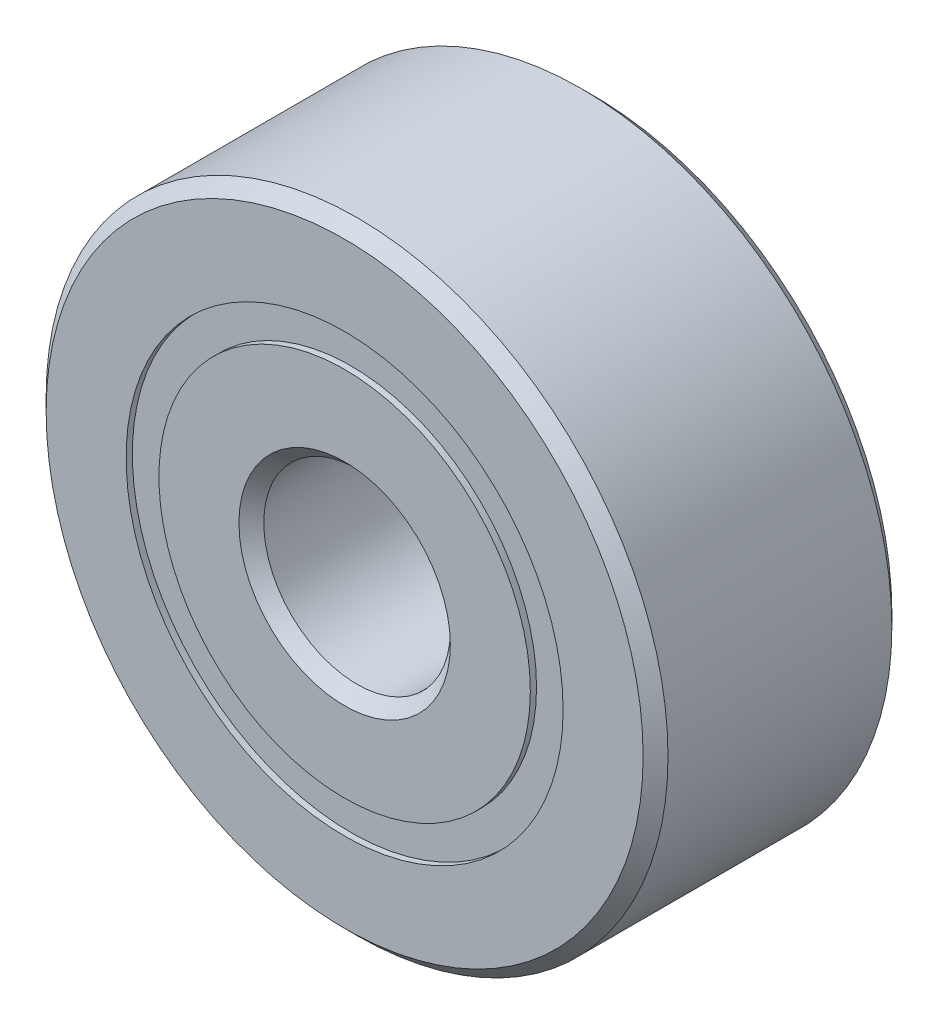
from build123d import *

# Parameters (mm, degrees)
CIRPATTERN1_COUNT = 12
SKETCH5_W         = 0.972810551
SKETCH5_H         = 0.527472528


with BuildPart() as part:
    # Sketch1 → Revolve1 (revolve)
    with BuildSketch(Plane(origin=(0, 0, 0), x_dir=(0, 0, -1), z_dir=(1, 0, 0))):
        with BuildLine():
            Line((1.8, 5), (-1.8, 5))
            Line((-1.8, 5), (-2, 4.8))
            Line((-2, 4.8), (-2, 3.513736264))
            Line((-2, 3.513736264), (-0.888888889, 3.513736264))
            ThreePointArc((-0.888888889, 3.513736264), (0, 4.177189449), (0.888888889, 3.513736264))
            Line((0.888888889, 3.513736264), (2, 3.513736264))
            Line((2, 3.513736264), (2, 4.8))
            Line((2, 4.8), (1.8, 5))
        make_face()
    revolve(axis=Axis((0, 0, 2), (0, 0, -1)))


with BuildPart() as body_2:
    # Sketch3 → Revolve3 (revolve)
    with BuildSketch(Plane(origin=(0, 0, 0), x_dir=(0, 0, -1), z_dir=(1, 0, 0))):
        with BuildLine():
            Line((-2, 2.986263736), (-0.888888889, 2.986263736))
            ThreePointArc((-0.888888889, 2.986263736), (0, 2.322810551), (0.888888889, 2.986263736))
            Line((0.888888889, 2.986263736), (2, 2.986263736))
            Line((2, 2.986263736), (2, 1.7))
            Line((2, 1.7), (1.8, 1.5))
            Line((1.8, 1.5), (-1.8, 1.5))
            Line((-1.8, 1.5), (-2, 1.7))
            Line((-2, 1.7), (-2, 2.986263736))
        make_face()
    revolve(axis=Axis((0, 0, 2), (0, 0, -1)))


with BuildPart() as body_3:
    # Sketch4 → Revolve4 (revolve)
    with BuildSketch(Plane(origin=(0, 0, 0), x_dir=(0, 0, -1), z_dir=(1, 0, 0))):
        with BuildLine():
            Line((-0.927189449, 3.25), (0.927189449, 3.25))
            ThreePointArc((0.927189449, 3.25), (0, 4.177189449), (-0.927189449, 3.25))
        make_face()
    revolve(axis=Axis((0, 3.25, 0.927189449), (0, 0, -1)))


with BuildPart() as cirpattern1_1:
    # CirPattern1: pattern copy
    add(body_3.part.rotate(Axis((0, 0, -2), (0, 0, 1)), 1 * 360 / CIRPATTERN1_COUNT))


with BuildPart() as cirpattern1_2:
    # CirPattern1: pattern copy
    add(body_3.part.rotate(Axis((0, 0, -2), (0, 0, 1)), 2 * 360 / CIRPATTERN1_COUNT))


with BuildPart() as cirpattern1_3:
    # CirPattern1: pattern copy
    add(body_3.part.rotate(Axis((0, 0, -2), (0, 0, 1)), 3 * 360 / CIRPATTERN1_COUNT))


with BuildPart() as cirpattern1_4:
    # CirPattern1: pattern copy
    add(body_3.part.rotate(Axis((0, 0, -2), (0, 0, 1)), 4 * 360 / CIRPATTERN1_COUNT))


with BuildPart() as cirpattern1_5:
    # CirPattern1: pattern copy
    add(body_3.part.rotate(Axis((0, 0, -2), (0, 0, 1)), 5 * 360 / CIRPATTERN1_COUNT))


with BuildPart() as cirpattern1_6:
    # CirPattern1: pattern copy
    add(body_3.part.rotate(Axis((0, 0, -2), (0, 0, 1)), 6 * 360 / CIRPATTERN1_COUNT))


with BuildPart() as cirpattern1_7:
    # CirPattern1: pattern copy
    add(body_3.part.rotate(Axis((0, 0, -2), (0, 0, 1)), 7 * 360 / CIRPATTERN1_COUNT))


with BuildPart() as cirpattern1_8:
    # CirPattern1: pattern copy
    add(body_3.part.rotate(Axis((0, 0, -2), (0, 0, 1)), 8 * 360 / CIRPATTERN1_COUNT))


with BuildPart() as cirpattern1_9:
    # CirPattern1: pattern copy
    add(body_3.part.rotate(Axis((0, 0, -2), (0, 0, 1)), 9 * 360 / CIRPATTERN1_COUNT))


with BuildPart() as cirpattern1_10:
    # CirPattern1: pattern copy
    add(body_3.part.rotate(Axis((0, 0, -2), (0, 0, 1)), 10 * 360 / CIRPATTERN1_COUNT))


with BuildPart() as cirpattern1_11:
    # CirPattern1: pattern copy
    add(body_3.part.rotate(Axis((0, 0, -2), (0, 0, 1)), 11 * 360 / CIRPATTERN1_COUNT))


with BuildPart() as body_15:
    # Sketch5 → Revolve5 (revolve)
    with BuildSketch(Plane(origin=(0, 0, 0), x_dir=(0, 0, -1), z_dir=(1, 0, 0))):
        with Locations((-1.413594725, 3.25)):
            Rectangle(SKETCH5_W, SKETCH5_H)
        with Locations((1.413594725, 3.25)):
            Rectangle(SKETCH5_W, SKETCH5_H)
    revolve(axis=Axis((0, 0, 2), (0, 0, -1)))


solid = Compound([part.part, body_2.part, body_3.part, cirpattern1_1.part, cirpattern1_2.part, cirpattern1_3.part, cirpattern1_4.part, cirpattern1_5.part, cirpattern1_6.part, cirpattern1_7.part, cirpattern1_8.part, cirpattern1_9.part, cirpattern1_10.part, cirpattern1_11.part, body_15.part])
